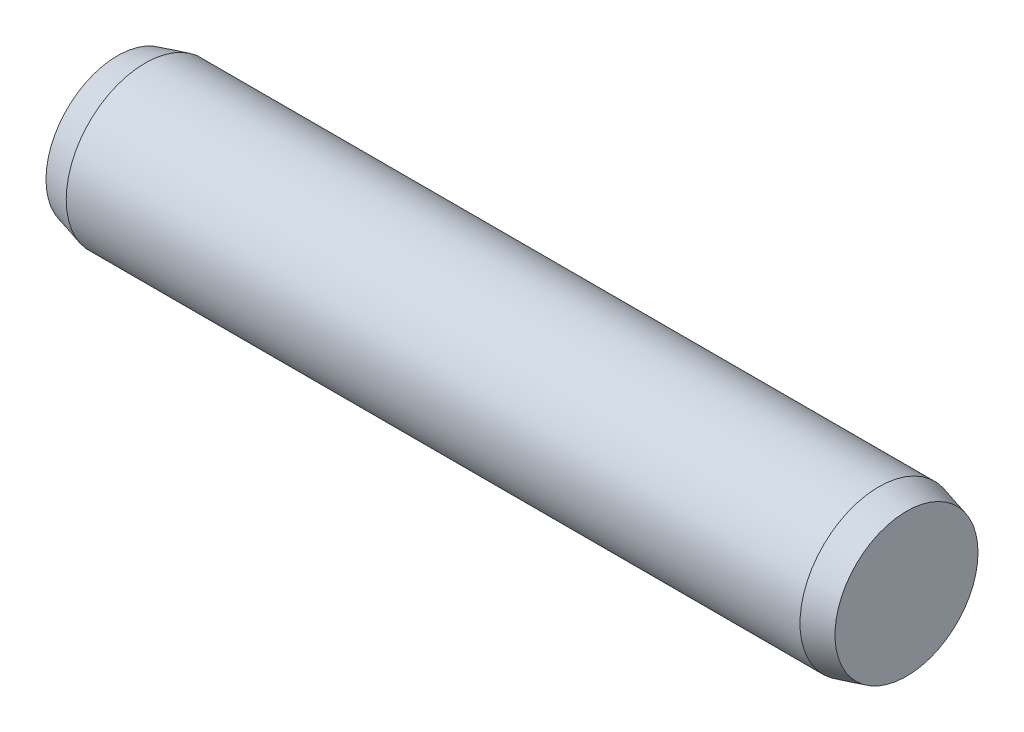
from build123d import *

# Parameters (mm, degrees)
SKETCH2_R           = 1
EXTRUDE1_DEPTH      = 4.65
EXTRUDE1_DEPTH_BACK = 4.65
SKETCH3_R           = 1
EXTRUDE2_DEPTH      = 0.35
EXTRUDE2_TAPER      = 15
SKETCH4_R           = 1
EXTRUDE3_DEPTH      = 0.35
EXTRUDE3_TAPER      = 15


with BuildPart() as part:
    # Sketch2 → Extrude1 (new body, two sides)
    with BuildSketch(Plane(origin=(0, 0, 0), x_dir=(0, 0, -1), z_dir=(1, 0, 0))) as extrude1_sk:
        Circle(SKETCH2_R)
    extrude(amount=EXTRUDE1_DEPTH)
    extrude(extrude1_sk.sketch, amount=-EXTRUDE1_DEPTH_BACK)

    # Sketch3 → Extrude2 (add)
    with BuildSketch(Plane(origin=(4.65, 0, 0), x_dir=(0, 0, -1), z_dir=(1, 0, 0))):
        Circle(SKETCH3_R)
    extrude(amount=EXTRUDE2_DEPTH, taper=EXTRUDE2_TAPER)

    # Sketch4 → Extrude3 (add)
    with BuildSketch(Plane.ZY.offset(4.65)):
        Circle(SKETCH4_R)
    extrude(amount=EXTRUDE3_DEPTH, taper=EXTRUDE3_TAPER)


solid = part.part
